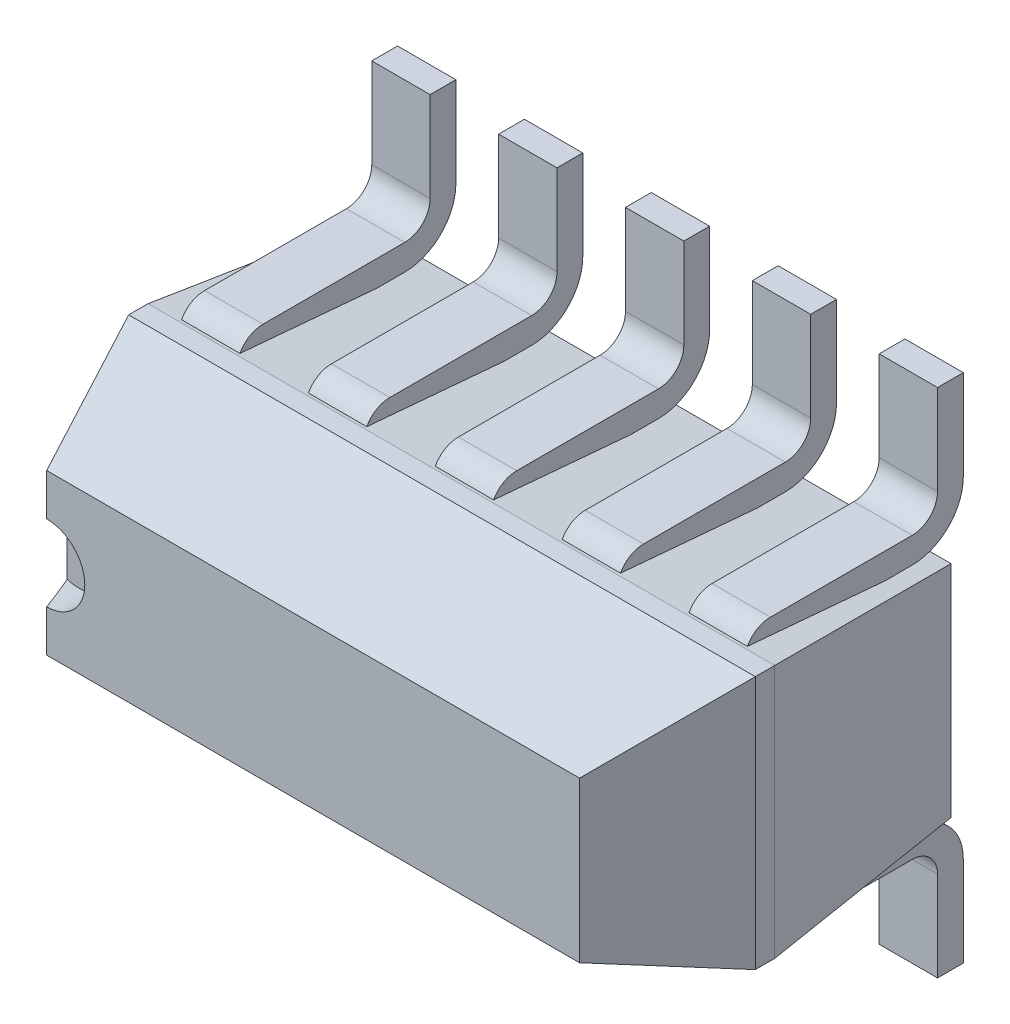
from build123d import *

# Parameters (mm, degrees)
SKETCH1_W                = 2.47
SKETCH1_H                = 1
BASE_EXTRUDE_DEPTH       = 1.3462
CHAMFER1_SIZE            = 0.508
CHAMFER1_SIZE2           = 0.184896879
CHAMFER1_PART_2_SIZE     = 0.508
CHAMFER1_PART_2_SIZE2    = 0.184896879
CHAMFER1_PART_3_SIZE     = 0.508
CHAMFER1_PART_3_SIZE2    = 0.184896879
CHAMFER1_PART_4_SIZE     = 0.508
CHAMFER1_PART_4_SIZE2    = 0.184896879
CHAMFER2_SIZE            = 0.762
CHAMFER2_SIZE2           = 0.066666362
CHAMFER2_PART_2_SIZE     = 0.762
CHAMFER2_PART_2_SIZE2    = 0.066666362
CHAMFER2_PART_3_SIZE     = 0.762
CHAMFER2_PART_3_SIZE2    = 0.066666362
CHAMFER2_PART_4_SIZE     = 0.762
CHAMFER2_PART_4_SIZE2    = 0.066666362
SKETCH3_R                = 0.15
CUT_EXTRUDE1_DEPTH       = 0.127
BOSS_EXTRUDE_THIN3_DEPTH = 0.115
LPATTERN1_COUNT          = 5
LPATTERN1_PITCH          = 0.5
MIRROR1_COPY_1_DEPTH     = 0.115
MIRROR1_COPY_2_DEPTH     = 0.115
MIRROR1_COPY_3_DEPTH     = 0.115
MIRROR1_COPY_4_DEPTH     = 0.115


with BuildPart() as part:
    # Sketch1 → Base-Extrude (new body)
    with BuildSketch(Plane.XY):
        with Locations((3.115498433, 1.262)):
            Rectangle(SKETCH1_W, SKETCH1_H)
    extrude(amount=BASE_EXTRUDE_DEPTH)

    # Chamfer1
    chamfer1_edges = [part.edges().sort_by_distance(p)[0] for p in [
        (4.350498433, 1.262, 1.3462),
    ]]
    chamfer1_side = [part.faces().sort_by_distance(p)[0] for p in [
        (4.350498433, 1.262, 0.6731),
    ]]
    chamfer(chamfer1_edges, length=CHAMFER1_SIZE, length2=CHAMFER1_SIZE2, reference=chamfer1_side[0])

    # Chamfer1 part 2
    chamfer1_part_2_edges = [part.edges().sort_by_distance(p)[0] for p in [
        (3.115498433, 1.762, 1.3462),
    ]]
    chamfer1_part_2_side = [part.faces().sort_by_distance(p)[0] for p in [
        (3.115498433, 1.762, 0.6731),
    ]]
    chamfer(chamfer1_part_2_edges, length=CHAMFER1_PART_2_SIZE, length2=CHAMFER1_PART_2_SIZE2, reference=chamfer1_part_2_side[0])

    # Chamfer1 part 3
    chamfer1_part_3_edges = [part.edges().sort_by_distance(p)[0] for p in [
        (1.880498433, 1.262, 1.3462),
    ]]
    chamfer1_part_3_side = [part.faces().sort_by_distance(p)[0] for p in [
        (1.880498433, 1.262, 0.6731),
    ]]
    chamfer(chamfer1_part_3_edges, length=CHAMFER1_PART_3_SIZE, length2=CHAMFER1_PART_3_SIZE2, reference=chamfer1_part_3_side[0])

    # Chamfer1 part 4
    chamfer1_part_4_edges = [part.edges().sort_by_distance(p)[0] for p in [
        (3.115498433, 0.762, 1.3462),
    ]]
    chamfer1_part_4_side = [part.faces().sort_by_distance(p)[0] for p in [
        (3.115498433, 0.762, 0.6731),
    ]]
    chamfer(chamfer1_part_4_edges, length=CHAMFER1_PART_4_SIZE, length2=CHAMFER1_PART_4_SIZE2, reference=chamfer1_part_4_side[0])

    # Chamfer2
    chamfer2_edges = [part.edges().sort_by_distance(p)[0] for p in [
        (3.115498433, 1.762, 0),
    ]]
    chamfer2_side = [part.faces().sort_by_distance(p)[0] for p in [
        (3.115498433, 1.762, 0.4191),
    ]]
    chamfer(chamfer2_edges, length=CHAMFER2_SIZE, length2=CHAMFER2_SIZE2, reference=chamfer2_side[0])

    # Chamfer2 part 2
    chamfer2_part_2_edges = [part.edges().sort_by_distance(p)[0] for p in [
        (4.350498433, 1.262, 0),
    ]]
    chamfer2_part_2_side = [part.faces().sort_by_distance(p)[0] for p in [
        (4.350498433, 1.262, 0.4191),
    ]]
    chamfer(chamfer2_part_2_edges, length=CHAMFER2_PART_2_SIZE, length2=CHAMFER2_PART_2_SIZE2, reference=chamfer2_part_2_side[0])

    # Chamfer2 part 3
    chamfer2_part_3_edges = [part.edges().sort_by_distance(p)[0] for p in [
        (3.115498433, 0.762, 0),
    ]]
    chamfer2_part_3_side = [part.faces().sort_by_distance(p)[0] for p in [
        (3.115498433, 0.762, 0.4191),
    ]]
    chamfer(chamfer2_part_3_edges, length=CHAMFER2_PART_3_SIZE, length2=CHAMFER2_PART_3_SIZE2, reference=chamfer2_part_3_side[0])

    # Chamfer2 part 4
    chamfer2_part_4_edges = [part.edges().sort_by_distance(p)[0] for p in [
        (1.880498433, 1.262, 0),
    ]]
    chamfer2_part_4_side = [part.faces().sort_by_distance(p)[0] for p in [
        (1.880498433, 1.262, 0.4191),
    ]]
    chamfer(chamfer2_part_4_edges, length=CHAMFER2_PART_4_SIZE, length2=CHAMFER2_PART_4_SIZE2, reference=chamfer2_part_4_side[0])

    # Sketch3 → Cut-Extrude1 (cut)
    with BuildSketch(Plane(origin=(0.118935742, 0.142956615, 1.3462), x_dir=(1, 0, 0), z_dir=(0, 0, 1))):
        with Locations((1.946665812, 1.119043385)):
            Circle(SKETCH3_R)
    extrude(amount=-CUT_EXTRUDE1_DEPTH, mode=Mode.SUBTRACT)

    # Sketch4 → Boss-Extrude-Thin3 (add, symmetric)
    with BuildSketch(Plane(origin=(2.115498433, 0, 0), x_dir=(0, 0, -1), z_dir=(1, 0, 0))):
        with BuildLine():
            ThreePointArc((-0.762, 0.812000071), (-0.73177342, 0.739026651), (-0.6588, 0.708800071))
            Line((-0.6588, 0.708800071), (-0.1, 0.708800071))
            ThreePointArc((-0.1, 0.708800071), (-0.029289322, 0.679510749), (0, 0.608800071))
            Line((0, 0.608800071), (0, 0.254259822))
            Line((0, 0.254259822), (0.1016, 0.254259822))
            Line((0.1016, 0.254259822), (0.1016, 0.608800071))
            ThreePointArc((0.1016, 0.608800071), (0.042552727, 0.751352798), (-0.1, 0.810400071))
            Line((-0.1, 0.810400071), (-0.6588, 0.810400071))
            ThreePointArc((-0.6588, 0.810400071), (-0.659931371, 0.8108687), (-0.6604, 0.812000071))
            Line((-0.6604, 0.812000071), (-0.762, 0.812000071))
        make_face()
    boss_extrude_thin3 = extrude(amount=BOSS_EXTRUDE_THIN3_DEPTH, both=True)

    # LPattern1: Boss-Extrude-Thin3 ×5
    with Locations(*[(i * LPATTERN1_PITCH, 0, 0) for i in range(1, LPATTERN1_COUNT)]):
        add(boss_extrude_thin3)

    # Mirror1: Boss-Extrude-Thin3 across plane
    add(boss_extrude_thin3.mirror(Plane.ZX.offset(1.262)))

    # Mirror1 copy 1 sketch → Mirror1 copy 1 (add, symmetric)
    with BuildSketch(Plane(origin=(2.615498433, 2.524, 0), x_dir=(0, 0, -1), z_dir=(1, 0, 0))):
        with BuildLine():
            ThreePointArc((-0.762, -0.812000071), (-0.73177342, -0.739026651), (-0.6588, -0.708800071))
            Line((-0.6588, -0.708800071), (-0.1, -0.708800071))
            ThreePointArc((-0.1, -0.708800071), (-0.029289322, -0.679510749), (0, -0.608800071))
            Line((0, -0.608800071), (0, -0.254259822))
            Line((0, -0.254259822), (0.1016, -0.254259822))
            Line((0.1016, -0.254259822), (0.1016, -0.608800071))
            ThreePointArc((0.1016, -0.608800071), (0.042552727, -0.751352798), (-0.1, -0.810400071))
            Line((-0.1, -0.810400071), (-0.6588, -0.810400071))
            ThreePointArc((-0.6588, -0.810400071), (-0.659931371, -0.8108687), (-0.6604, -0.812000071))
            Line((-0.6604, -0.812000071), (-0.762, -0.812000071))
        make_face()
    extrude(amount=MIRROR1_COPY_1_DEPTH, both=True)

    # Mirror1 copy 2 sketch → Mirror1 copy 2 (add, symmetric)
    with BuildSketch(Plane(origin=(3.115498433, 2.524, 0), x_dir=(0, 0, -1), z_dir=(1, 0, 0))):
        with BuildLine():
            ThreePointArc((-0.762, -0.812000071), (-0.73177342, -0.739026651), (-0.6588, -0.708800071))
            Line((-0.6588, -0.708800071), (-0.1, -0.708800071))
            ThreePointArc((-0.1, -0.708800071), (-0.029289322, -0.679510749), (0, -0.608800071))
            Line((0, -0.608800071), (0, -0.254259822))
            Line((0, -0.254259822), (0.1016, -0.254259822))
            Line((0.1016, -0.254259822), (0.1016, -0.608800071))
            ThreePointArc((0.1016, -0.608800071), (0.042552727, -0.751352798), (-0.1, -0.810400071))
            Line((-0.1, -0.810400071), (-0.6588, -0.810400071))
            ThreePointArc((-0.6588, -0.810400071), (-0.659931371, -0.8108687), (-0.6604, -0.812000071))
            Line((-0.6604, -0.812000071), (-0.762, -0.812000071))
        make_face()
    extrude(amount=MIRROR1_COPY_2_DEPTH, both=True)

    # Mirror1 copy 3 sketch → Mirror1 copy 3 (add, symmetric)
    with BuildSketch(Plane(origin=(3.615498433, 2.524, 0), x_dir=(0, 0, -1), z_dir=(1, 0, 0))):
        with BuildLine():
            ThreePointArc((-0.762, -0.812000071), (-0.73177342, -0.739026651), (-0.6588, -0.708800071))
            Line((-0.6588, -0.708800071), (-0.1, -0.708800071))
            ThreePointArc((-0.1, -0.708800071), (-0.029289322, -0.679510749), (0, -0.608800071))
            Line((0, -0.608800071), (0, -0.254259822))
            Line((0, -0.254259822), (0.1016, -0.254259822))
            Line((0.1016, -0.254259822), (0.1016, -0.608800071))
            ThreePointArc((0.1016, -0.608800071), (0.042552727, -0.751352798), (-0.1, -0.810400071))
            Line((-0.1, -0.810400071), (-0.6588, -0.810400071))
            ThreePointArc((-0.6588, -0.810400071), (-0.659931371, -0.8108687), (-0.6604, -0.812000071))
            Line((-0.6604, -0.812000071), (-0.762, -0.812000071))
        make_face()
    extrude(amount=MIRROR1_COPY_3_DEPTH, both=True)

    # Mirror1 copy 4 sketch → Mirror1 copy 4 (add, symmetric)
    with BuildSketch(Plane(origin=(4.115498433, 2.524, 0), x_dir=(0, 0, -1), z_dir=(1, 0, 0))):
        with BuildLine():
            ThreePointArc((-0.762, -0.812000071), (-0.73177342, -0.739026651), (-0.6588, -0.708800071))
            Line((-0.6588, -0.708800071), (-0.1, -0.708800071))
            ThreePointArc((-0.1, -0.708800071), (-0.029289322, -0.679510749), (0, -0.608800071))
            Line((0, -0.608800071), (0, -0.254259822))
            Line((0, -0.254259822), (0.1016, -0.254259822))
            Line((0.1016, -0.254259822), (0.1016, -0.608800071))
            ThreePointArc((0.1016, -0.608800071), (0.042552727, -0.751352798), (-0.1, -0.810400071))
            Line((-0.1, -0.810400071), (-0.6588, -0.810400071))
            ThreePointArc((-0.6588, -0.810400071), (-0.659931371, -0.8108687), (-0.6604, -0.812000071))
            Line((-0.6604, -0.812000071), (-0.762, -0.812000071))
        make_face()
    extrude(amount=MIRROR1_COPY_4_DEPTH, both=True)


solid = part.part
